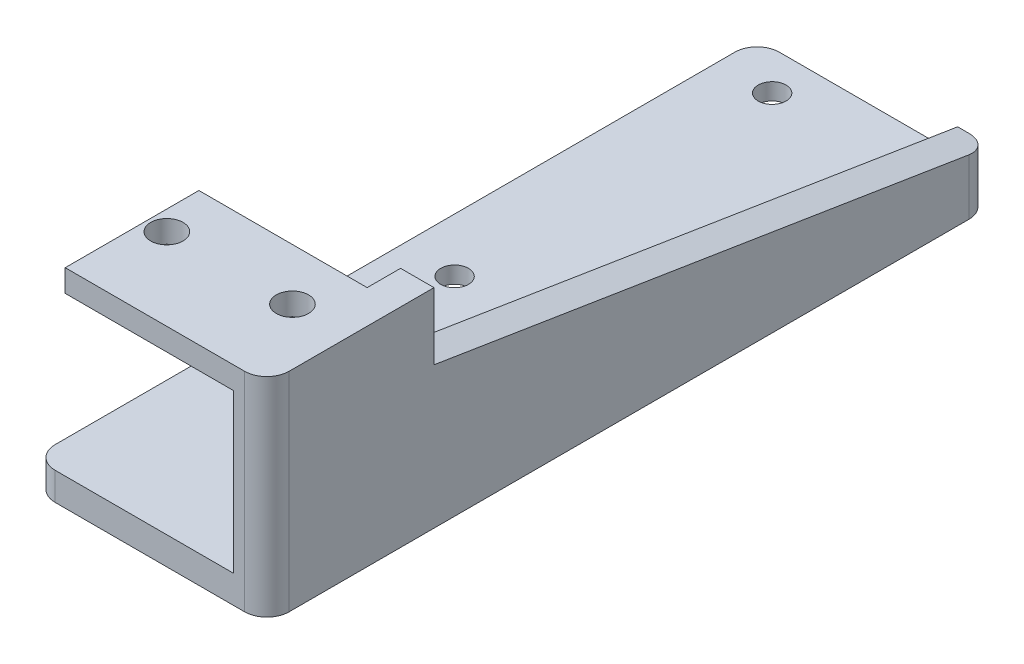
from build123d import *

# Parameters (mm, degrees)
EXTRUDE_1_DEPTH     = 65
CUT_EXTRUDE_1_REACH = 20.7
SKETCH_2_R          = 1.45
SKETCH_2_W          = 15.1
SKETCH_2_H          = 53
CUT_EXTRUDE_2_REACH = 4.5
SKETCH_3_R          = 1.25
CUT_EXTRUDE_3_REACH = 23
FILLET_1_R          = 2
SKETCH_5_R          = 2.7
CUT_EXTRUDE_4_DEPTH = 1


with BuildPart() as part:
    # 草图1 → 凸台-拉伸1 (new body)
    with BuildSketch(Plane.XY):
        Polygon((0, 2), (0, 0), (15.1, 0), (15.1, -14.2), (-2.9, -14.2), (-2.9, -16.7), (18.1, -16.7), (18.1, 2), align=None)
    extrude(amount=EXTRUDE_1_DEPTH)

    # 草图2 → 切除-拉伸1 (cut, up to next)
    with BuildSketch(Plane(origin=(0, 2, 0), x_dir=(1, 0, 0), z_dir=(0, 1, 0)), mode=Mode.PRIVATE) as cut_extrude_1_sk1:
        with Locations((1.765, -57.64)):
            Circle(SKETCH_2_R)
    cut_extrude_1_tool1 = extrude(cut_extrude_1_sk1.sketch, amount=-CUT_EXTRUDE_1_REACH, mode=Mode.PRIVATE) & part.part
    add(cut_extrude_1_tool1.solids().sort_by_distance((1.765, 2, 57.64))[0], mode=Mode.SUBTRACT)
    # 草图2 → 切除-拉伸1 (cut, up to next)
    with BuildSketch(Plane(origin=(0, 2, 0), x_dir=(1, 0, 0), z_dir=(0, 1, 0)), mode=Mode.PRIVATE) as cut_extrude_1_sk2:
        with Locations((13.035, -57.64)):
            Circle(SKETCH_2_R)
    cut_extrude_1_tool2 = extrude(cut_extrude_1_sk2.sketch, amount=-CUT_EXTRUDE_1_REACH, mode=Mode.PRIVATE) & part.part
    add(cut_extrude_1_tool2.solids().sort_by_distance((13.035, 2, 57.64))[0], mode=Mode.SUBTRACT)
    # 草图2 → 切除-拉伸1 (cut, up to next)
    with BuildSketch(Plane(origin=(0, 2, 0), x_dir=(1, 0, 0), z_dir=(0, 1, 0)), mode=Mode.PRIVATE) as cut_extrude_1_sk3:
        with Locations((7.55, -26.5)):
            Rectangle(SKETCH_2_W, SKETCH_2_H)
    cut_extrude_1_tool3 = extrude(cut_extrude_1_sk3.sketch, amount=-CUT_EXTRUDE_1_REACH, mode=Mode.PRIVATE) & part.part
    add(cut_extrude_1_tool3.solids().sort_by_distance((7.55, 2, 26.5))[0], mode=Mode.SUBTRACT)

    # 草图3 → 切除-拉伸2 (cut, up to next)
    with BuildSketch(Plane(origin=(0, -14.2, 0), x_dir=(1, 0, 0), z_dir=(0, 1, 0)), mode=Mode.PRIVATE) as cut_extrude_2_sk1:
        with Locations((1.95, -3.5)):
            Circle(SKETCH_3_R)
    cut_extrude_2_tool1 = extrude(cut_extrude_2_sk1.sketch, amount=-CUT_EXTRUDE_2_REACH, mode=Mode.PRIVATE) & part.part
    add(cut_extrude_2_tool1.solids().sort_by_distance((1.95, -14.2, 3.5))[0], mode=Mode.SUBTRACT)
    # 草图3 → 切除-拉伸2 (cut, up to next)
    with BuildSketch(Plane(origin=(0, -14.2, 0), x_dir=(1, 0, 0), z_dir=(0, 1, 0)), mode=Mode.PRIVATE) as cut_extrude_2_sk2:
        with Locations((1.95, -32)):
            Circle(SKETCH_3_R)
    cut_extrude_2_tool2 = extrude(cut_extrude_2_sk2.sketch, amount=-CUT_EXTRUDE_2_REACH, mode=Mode.PRIVATE) & part.part
    add(cut_extrude_2_tool2.solids().sort_by_distance((1.95, -14.2, 32))[0], mode=Mode.SUBTRACT)

    # 草图4 → 切除-拉伸3 (cut, up to next)
    with BuildSketch(Plane(origin=(18.1, 0, 0), x_dir=(0, 0, -1), z_dir=(1, 0, 0)), mode=Mode.PRIVATE) as cut_extrude_3_sk1:
        Polygon((-50, 2), (0, 2), (0, -12), (-50, -4), align=None)
    cut_extrude_3_tool1 = extrude(cut_extrude_3_sk1.sketch, amount=-CUT_EXTRUDE_3_REACH, mode=Mode.PRIVATE) & part.part
    add(cut_extrude_3_tool1.solids().sort_by_distance((18.1, -3.266667, 21.666667))[0], mode=Mode.SUBTRACT)

    # 圆角1
    fillet_1_edges = [part.edges().sort_by_distance(p)[0] for p in [
        (-2.9, -15.45, 65),
        (18.1, -7.35, 65),
        (18.1, -14.35, 0),
        (-2.9, -15.45, 0),
    ]]
    fillet(fillet_1_edges, radius=FILLET_1_R)

    # 草图5 → 切除-拉伸4 (cut)
    with BuildSketch(Plane.XZ.offset(16.7)):
        with Locations((1.95, 32)):
            Circle(SKETCH_5_R)
        with Locations((1.95, 3.5)):
            Circle(SKETCH_5_R)
    extrude(amount=-CUT_EXTRUDE_4_DEPTH, mode=Mode.SUBTRACT)


solid = part.part
